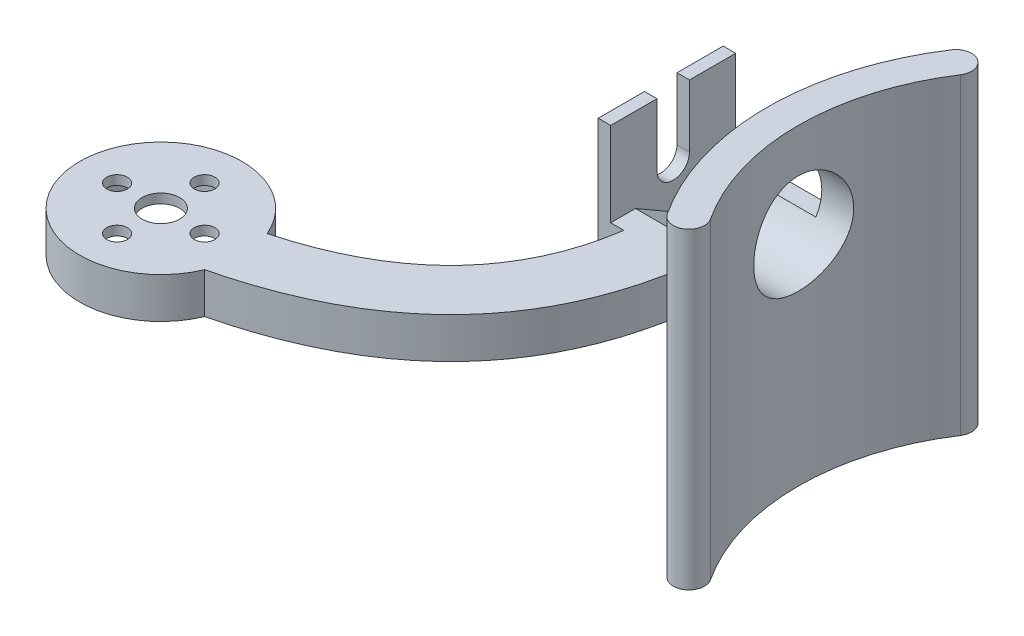
from build123d import *

# Parameters (mm, degrees)
BOSS_EXTRU_1_DEPTH      = 50
ESQUISSE2_R             = 8
ENL_V_MAT_EXTRU_1_DEPTH = 42.5
BOSS_EXTRU_3_DEPTH      = 2
BOSS_EXTRU_4_DEPTH      = 8
BOSS_EXTRU_5_DEPTH      = 8.222835
ESQUISSE8_R             = 1.65
ESQUISSE8_R_2           = 3
BOSS_EXTRU_6_DEPTH      = 6.507031
ESQUISSE9_R             = 10.5
ENL_V_MAT_EXTRU_2_DEPTH = 5.007031


with BuildPart() as part:
    # Esquisse1 → Boss.-Extru.1 (new body)
    with BuildSketch(Plane(origin=(0, 0, 0), x_dir=(1, 0, 0), z_dir=(0, 1, 0))):
        with BuildLine():
            ThreePointArc((-34.715340416, 22.739726027), (-41.5, 0), (-34.715340416, -22.739726027))
            ThreePointArc((-34.715340416, -22.739726027), (-31.254191835, -23.461148581), (-30.532769282, -20))
            ThreePointArc((-30.532769282, -20), (-36.5, 0), (-30.532769282, 20))
            ThreePointArc((-30.532769282, 20), (-31.254191835, 23.461148581), (-34.715340416, 22.739726027))
        make_face()
    extrude(amount=BOSS_EXTRU_1_DEPTH)

    # Esquisse2 → Enlèv. mat.-Extru.1 (cut, through all)
    with BuildSketch(Plane(origin=(0, 0, 0), x_dir=(0, 0, -1), z_dir=(1, 0, 0))):
        with Locations((0, 35)):
            Circle(ESQUISSE2_R)
    extrude(amount=-ENL_V_MAT_EXTRU_1_DEPTH, mode=Mode.SUBTRACT)



with BuildPart() as body_2:
    # Esquisse4 → Boss.-Extru.3 (new body)
    with BuildSketch(Plane.ZY.offset(56.5)):
        with BuildLine():
            Line((-2.6, 35), (-2.6, 45))
            Line((-2.6, 45), (-10, 45))
            Line((-10, 45), (-10, 25))
            Line((-10, 25), (10, 25))
            Line((10, 25), (10, 45))
            Line((10, 45), (2.6, 45))
            Line((2.6, 45), (2.6, 35))
            ThreePointArc((2.6, 35), (0, 32.4), (-2.6, 35))
        make_face()
    extrude(amount=BOSS_EXTRU_3_DEPTH)

    # Esquisse6 → Boss.-Extru.4 (add)
    with BuildSketch(Plane.ZY.offset(56.5)):
        Polygon((6.05, 31.507030871), (0, 28.014061743), (-6.05, 31.507030871), (-10, 31.507030871), (-10, 25), (10, 25), (10, 31.507030871), align=None)
    extrude(amount=-BOSS_EXTRU_4_DEPTH)


with BuildPart() as part_1:
    add(part.part)

    add(body_2.part)  # Boss.-Extru.5 merges body 2
    # Esquisse7 → Boss.-Extru.5 (add)
    with BuildSketch(Plane(origin=(-48.5, 0, 0), x_dir=(0, 0, -1), z_dir=(1, 0, 0))):
        with BuildLine():
            Line((10, 31.507030871), (7.197163793, 31.507030871))
            ThreePointArc((7.197163793, 31.507030871), (0, 27), (-7.197163793, 31.507030871))
            Line((-7.197163793, 31.507030871), (-10, 31.507030871))
            Line((-10, 31.507030871), (-10, 25))
            Line((-10, 25), (10, 25))
            Line((10, 25), (10, 31.507030871))
        make_face()
    extrude(amount=BOSS_EXTRU_5_DEPTH)

    # Esquisse8 → Boss.-Extru.6 (add)
    with BuildSketch(Plane.XZ.offset(-25)):
        with BuildLine():
            Line((-54.388582373, 10), (-44.388582373, 10))
            add(Edge.make_bspline(
                [(-82.50013532, 49), (-49.000452969, 40.897437534), (-44.388582373, 10)],
                knots=[0, 0, 0, 1, 1, 1], degree=2))
            ThreePointArc((-82.50013532, 49), (-107.50013532, 44), (-82.50013532, 39))
            add(Edge.make_bspline(
                [(-82.50013532, 39), (-57.708994437, 32.301835207), (-54.388582373, 10)],
                knots=[0, 0, 0, 1, 1, 1], degree=2))
        make_face()
        with Locations((-87.50013532, 44)):
            Circle(ESQUISSE8_R, mode=Mode.SUBTRACT)
        with Locations((-94.50013532, 37)):
            Circle(ESQUISSE8_R, mode=Mode.SUBTRACT)
        with Locations((-101.50013532, 44)):
            Circle(ESQUISSE8_R, mode=Mode.SUBTRACT)
        with Locations((-94.50013532, 51)):
            Circle(ESQUISSE8_R, mode=Mode.SUBTRACT)
        with Locations((-94.50013532, 44)):
            Circle(ESQUISSE8_R_2, mode=Mode.SUBTRACT)
    extrude(amount=-BOSS_EXTRU_6_DEPTH)

    # Esquisse9 → Enlèv. mat.-Extru.2 (cut)
    with BuildSketch(Plane.XZ.offset(-25)):
        with Locations((-94.50013532, 44)):
            Circle(ESQUISSE9_R)
    extrude(amount=-ENL_V_MAT_EXTRU_2_DEPTH, mode=Mode.SUBTRACT)


solid = part_1.part
